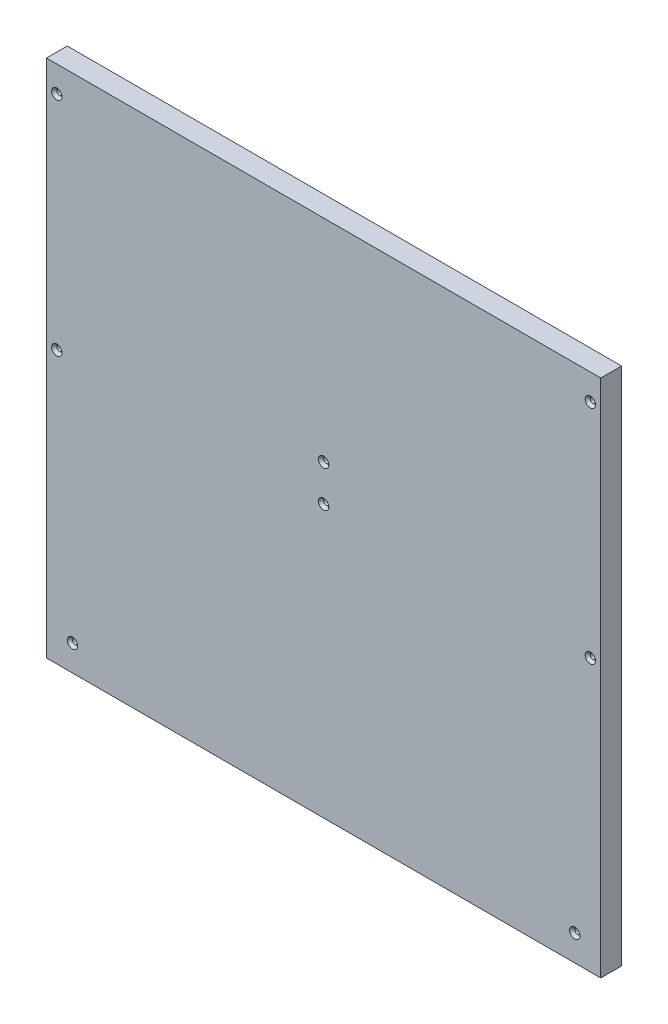
from build123d import *

# Parameters (mm, degrees)
SKETCH1_W           = 320
SKETCH1_H           = 300
SKETCH1_R           = 1.5
BOSS_EXTRUDE1_DEPTH = 12


with BuildPart() as part:
    # Sketch1 → Boss-Extrude1 (new body)
    with BuildSketch(Plane.XY):
        with Locations((14.507772021, 90.725388601)):
            Rectangle(SKETCH1_W, SKETCH1_H)
        with Locations((-139.492227979, 225.725388601)):
            Circle(SKETCH1_R, mode=Mode.SUBTRACT)
        with Locations((-139.492227979, 97.725388601)):
            Circle(SKETCH1_R, mode=Mode.SUBTRACT)
        with Locations((168.507772021, 225.725388601)):
            Circle(SKETCH1_R, mode=Mode.SUBTRACT)
        with Locations((168.507772021, 97.725388601)):
            Circle(SKETCH1_R, mode=Mode.SUBTRACT)
        with Locations((-130.492227979, -44.274611399)):
            Circle(SKETCH1_R, mode=Mode.SUBTRACT)
        with Locations((159.507772021, -44.274611399)):
            Circle(SKETCH1_R, mode=Mode.SUBTRACT)
        with Locations((14.507772021, 97.725388601)):
            Circle(SKETCH1_R, mode=Mode.SUBTRACT)
        with Locations((14.507772021, 118.725388601)):
            Circle(SKETCH1_R, mode=Mode.SUBTRACT)
    extrude(amount=BOSS_EXTRUDE1_DEPTH)

    # Cut-Extrude1 cone 1 section (through the dimple's axis) → Cut-Extrude1 (revolve, cut)
    with BuildSketch(Plane(origin=(-139.492227979, 225.725388601, 12), x_dir=(0, -1, 0), z_dir=(1, 0, 0))):
        Polygon((0, 0), (3, 0), (0, 3), align=None)
    revolve(axis=Axis((-139.492227979, 225.725388601, 12), (0, 0, -1)), mode=Mode.SUBTRACT)

    # Cut-Extrude1 cone 2 section (through the dimple's axis) → Cut-Extrude1 cone 2 (revolve, cut)
    with BuildSketch(Plane(origin=(-139.492227979, 97.725388601, 12), x_dir=(0, -1, 0), z_dir=(1, 0, 0))):
        Polygon((0, 0), (3, 0), (0, 3), align=None)
    revolve(axis=Axis((-139.492227979, 97.725388601, 12), (0, 0, -1)), mode=Mode.SUBTRACT)

    # Cut-Extrude1 cone 3 section (through the dimple's axis) → Cut-Extrude1 cone 3 (revolve, cut)
    with BuildSketch(Plane(origin=(168.507772021, 225.725388601, 12), x_dir=(0, -1, 0), z_dir=(1, 0, 0))):
        Polygon((0, 0), (3, 0), (0, 3), align=None)
    revolve(axis=Axis((168.507772021, 225.725388601, 12), (0, 0, -1)), mode=Mode.SUBTRACT)

    # Cut-Extrude1 cone 4 section (through the dimple's axis) → Cut-Extrude1 cone 4 (revolve, cut)
    with BuildSketch(Plane(origin=(168.507772021, 97.725388601, 12), x_dir=(0, -1, 0), z_dir=(1, 0, 0))):
        Polygon((0, 0), (3, 0), (0, 3), align=None)
    revolve(axis=Axis((168.507772021, 97.725388601, 12), (0, 0, -1)), mode=Mode.SUBTRACT)

    # Cut-Extrude1 cone 5 section (through the dimple's axis) → Cut-Extrude1 cone 5 (revolve, cut)
    with BuildSketch(Plane(origin=(14.507772021, 97.725388601, 12), x_dir=(0, -1, 0), z_dir=(1, 0, 0))):
        Polygon((0, 0), (3, 0), (0, 3), align=None)
    revolve(axis=Axis((14.507772021, 97.725388601, 12), (0, 0, -1)), mode=Mode.SUBTRACT)

    # Cut-Extrude1 cone 6 section (through the dimple's axis) → Cut-Extrude1 cone 6 (revolve, cut)
    with BuildSketch(Plane(origin=(159.507772021, -44.274611399, 12), x_dir=(0, -1, 0), z_dir=(1, 0, 0))):
        Polygon((0, 0), (3, 0), (0, 3), align=None)
    revolve(axis=Axis((159.507772021, -44.274611399, 12), (0, 0, -1)), mode=Mode.SUBTRACT)

    # Cut-Extrude1 cone 7 section (through the dimple's axis) → Cut-Extrude1 cone 7 (revolve, cut)
    with BuildSketch(Plane(origin=(-130.492227979, -44.274611399, 12), x_dir=(0, -1, 0), z_dir=(1, 0, 0))):
        Polygon((0, 0), (3, 0), (0, 3), align=None)
    revolve(axis=Axis((-130.492227979, -44.274611399, 12), (0, 0, -1)), mode=Mode.SUBTRACT)

    # Cut-Extrude1 cone 8 section (through the dimple's axis) → Cut-Extrude1 cone 8 (revolve, cut)
    with BuildSketch(Plane(origin=(14.507772021, 118.725388601, 12), x_dir=(0, -1, 0), z_dir=(1, 0, 0))):
        Polygon((0, 0), (3, 0), (0, 3), align=None)
    revolve(axis=Axis((14.507772021, 118.725388601, 12), (0, 0, -1)), mode=Mode.SUBTRACT)


solid = part.part
